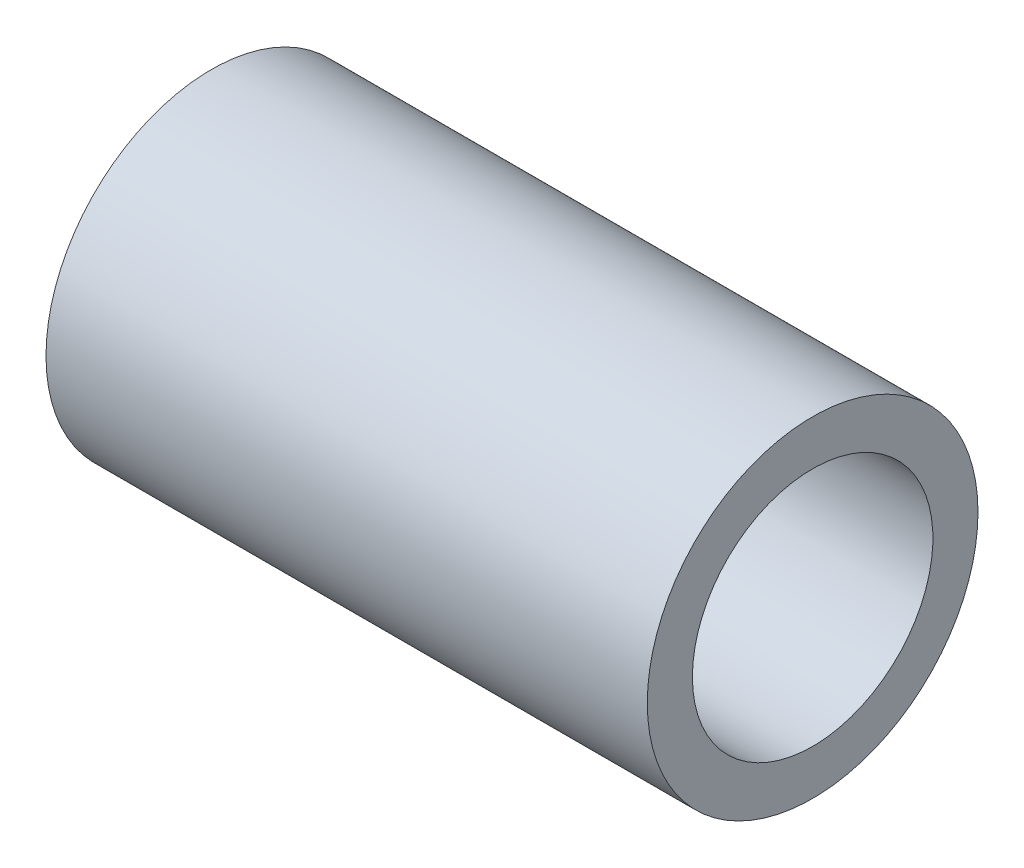
from build123d import *

# Parameters (mm, degrees)
SKETCH2_W = 20
SKETCH2_H = 1.5


with BuildPart() as part:
    # Sketch2 → Revolve1 (revolve)
    with BuildSketch(Plane.XY):
        with Locations((12, 4.75)):
            Rectangle(SKETCH2_W, SKETCH2_H)
    revolve(axis=Axis((0, 0, 0), (1, 0, 0)))


solid = part.part
